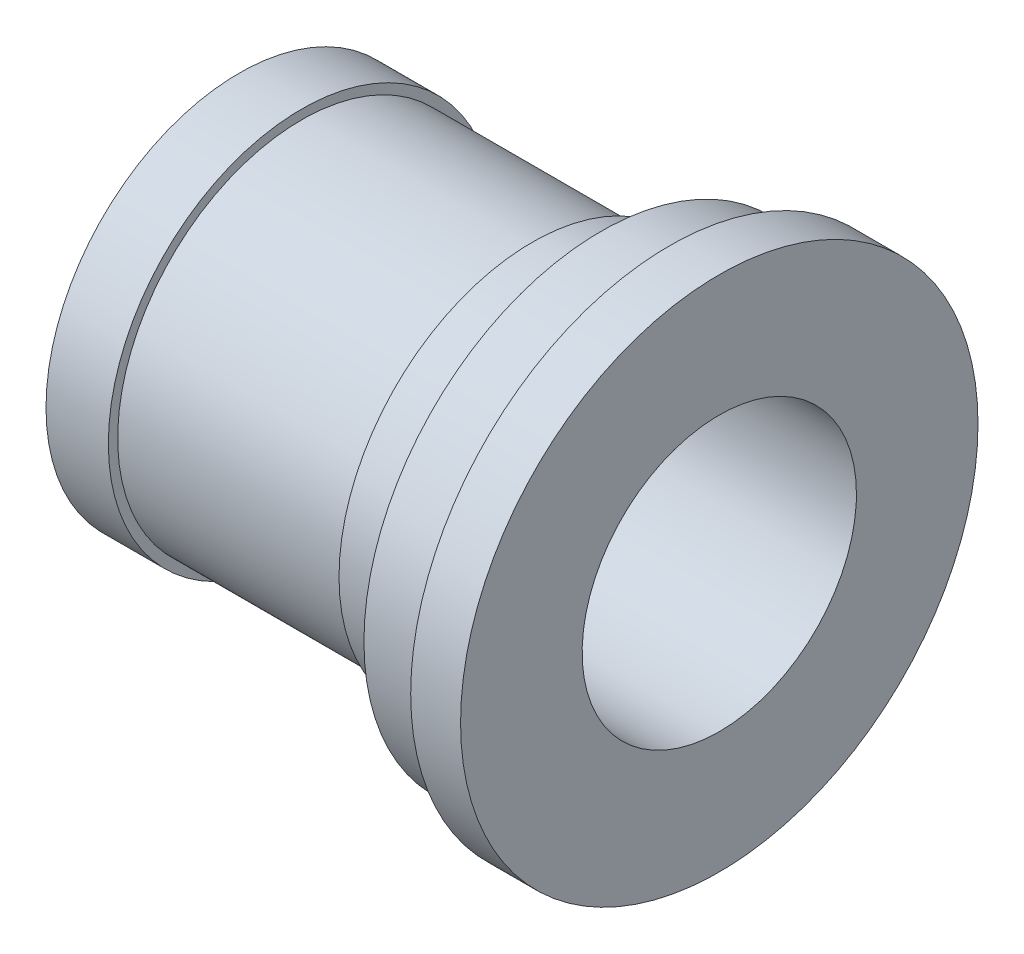
from build123d import *

# Parameters (mm, degrees)
SKETCH1_R           = 31
SKETCH1_R_2         = 22
BOSS_EXTRUDE1_DEPTH = 10
SKETCH2_R           = 29.5
SKETCH2_R_2         = 22
BOSS_EXTRUDE2_DEPTH = 37
SKETCH3_R           = 31
SKETCH3_R_2         = 22
BOSS_EXTRUDE3_DEPTH = 11
SKETCH4_R           = 38
SKETCH4_R_2         = 22
BOSS_EXTRUDE4_DEPTH = 11
SKETCH5_R           = 41.5
SKETCH5_R_2         = 22
BOSS_EXTRUDE5_DEPTH = 8
SKETCH6_R           = 1.5
CUT_EXTRUDE2_DEPTH  = 5


with BuildPart() as part:
    # Sketch1 → Boss-Extrude1 (new body)
    with BuildSketch(Plane(origin=(0, 0, 0), x_dir=(0, 0, -1), z_dir=(1, 0, 0))):
        Circle(SKETCH1_R)
        Circle(SKETCH1_R_2, mode=Mode.SUBTRACT)
    extrude(amount=BOSS_EXTRUDE1_DEPTH)

    # Sketch2 → Boss-Extrude2 (add)
    with BuildSketch(Plane(origin=(10, 0, 0), x_dir=(0, 0, -1), z_dir=(1, 0, 0))):
        Circle(SKETCH2_R)
        Circle(SKETCH2_R_2, mode=Mode.SUBTRACT)
    extrude(amount=BOSS_EXTRUDE2_DEPTH)

    # Sketch3 → Boss-Extrude3 (add)
    with BuildSketch(Plane(origin=(47, 0, 0), x_dir=(0, 0, -1), z_dir=(1, 0, 0))):
        Circle(SKETCH3_R)
        Circle(SKETCH3_R_2, mode=Mode.SUBTRACT)
    extrude(amount=BOSS_EXTRUDE3_DEPTH)

    # Sketch4 → Boss-Extrude4 (add)
    with BuildSketch(Plane(origin=(58, 0, 0), x_dir=(0, 0, -1), z_dir=(1, 0, 0))):
        Circle(SKETCH4_R)
        Circle(SKETCH4_R_2, mode=Mode.SUBTRACT)
    extrude(amount=BOSS_EXTRUDE4_DEPTH)

    # Sketch5 → Boss-Extrude5 (add)
    with BuildSketch(Plane(origin=(69, 0, 0), x_dir=(0, 0, -1), z_dir=(1, 0, 0))):
        Circle(SKETCH5_R)
        Circle(SKETCH5_R_2, mode=Mode.SUBTRACT)
    extrude(amount=BOSS_EXTRUDE5_DEPTH)

    # Sketch6 → Cut-Extrude2 (cut)
    with BuildSketch(Plane.ZY):
        with Locations((-22, 0)):
            Circle(SKETCH6_R)
    extrude(amount=-CUT_EXTRUDE2_DEPTH, mode=Mode.SUBTRACT)


solid = part.part
